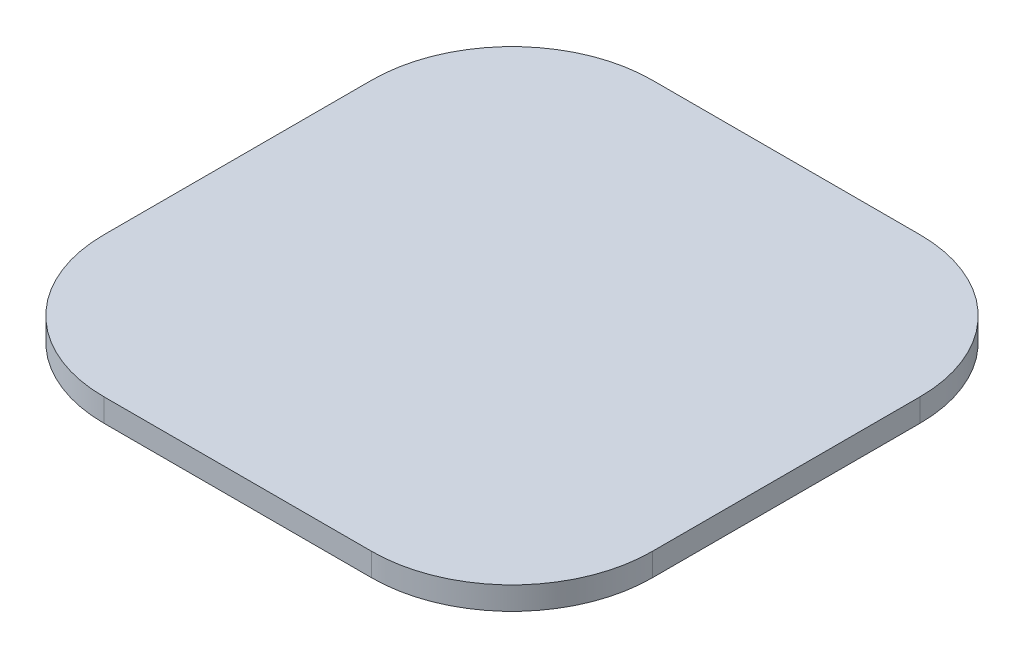
from build123d import *

# Parameters (mm, degrees)
BOSS_EXTRUDE1_DEPTH = 1.8


with BuildPart() as part:
    # Sketch1 → Boss-Extrude1 (new body)
    with BuildSketch(Plane(origin=(0, 0, 0), x_dir=(1, 0, 0), z_dir=(0, 1, 0))):
        with BuildLine():
            Line((10.5, -21.5), (-10.5, -21.5))
            ThreePointArc((-10.5, -21.5), (-18.278174593, -18.278174593), (-21.5, -10.5))
            Line((-21.5, -10.5), (-21.5, 10.5))
            ThreePointArc((-21.5, 10.5), (-18.278174593, 18.278174593), (-10.5, 21.5))
            Line((-10.5, 21.5), (10.5, 21.5))
            ThreePointArc((10.5, 21.5), (18.278174593, 18.278174593), (21.5, 10.5))
            Line((21.5, 10.5), (21.5, -10.5))
            ThreePointArc((21.5, -10.5), (18.278174593, -18.278174593), (10.5, -21.5))
        make_face()
    extrude(amount=BOSS_EXTRUDE1_DEPTH)


solid = part.part
